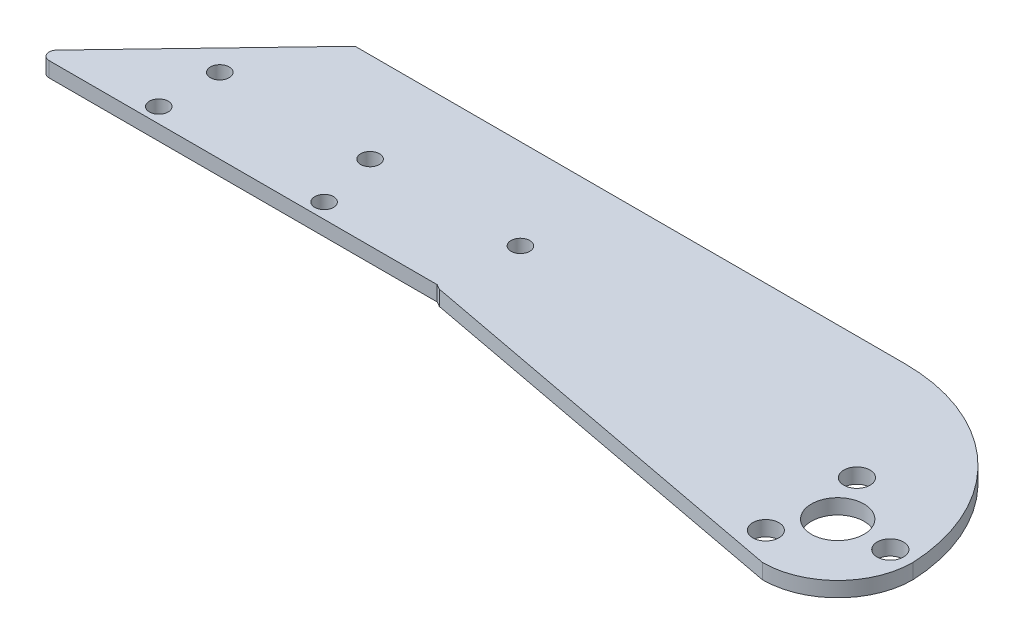
from build123d import *

# Parameters (mm, degrees)
SKETCH1_R                = 1.25
SKETCH1_R_2              = 1.75
BOSS_EXTRUDE1_DEPTH      = 2
FILLET_1_R               = 1
SKETCH_1_R               = 1.25
CUT_EXTRUDE_1_DEPTH      = 1
CUT_EXTRUDE_1_DEPTH_BACK = 3


with BuildPart() as part:
    # Sketch1 → Boss-Extrude1 (new body)
    with BuildSketch(Plane(origin=(0, 0, 0), x_dir=(1, 0, 0), z_dir=(0, 1, 0))):
        with BuildLine():
            Line((-13.417150151, 22.383876488), (-69.977405348, 22.383876488))
            Line((-69.977405348, 22.383876488), (-86.593533576, 22.383876488))
            Line((-86.593533576, 22.383876488), (-107.641374678, 0.375))
            Line((-107.641374678, 0.375), (-53.661481565, 0.375))
            Line((-53.661481565, 0.375), (-53, 0))
            Line((-53, 0), (0, -10))
            Line((0, -10), (0, -3.5))
            ThreePointArc((0, -3.5), (-3.5, 0), (0, 3.5))
            Line((0, 3.5), (0, 10))
            ThreePointArc((0, 10), (6.493821579, 7.604622364), (9.876612161, 1.566056261))
            ThreePointArc((9.876612161, 1.566056261), (2.20319717, 16.421011896), (-13.417150151, 22.383876488))
        make_face()
        with Locations((-92.705183178, 2.375)):
            Circle(SKETCH1_R, mode=Mode.SUBTRACT)
        with Locations((-70.705183178, 2.375)):
            Circle(SKETCH1_R, mode=Mode.SUBTRACT)
        with Locations((-3.5, -6.062177826)):
            Circle(SKETCH1_R_2, mode=Mode.SUBTRACT)
        with Locations((-3.5, 6.062177826)):
            Circle(SKETCH1_R_2, mode=Mode.SUBTRACT)
        with BuildLine():
            ThreePointArc((10, 0), (9.951428515, 0.784062032), (9.876612161, 1.566056261))
            ThreePointArc((9.876612161, 1.566056261), (6.493821579, 7.604622364), (0, 10))
            Line((0, 10), (0, 3.5))
            ThreePointArc((0, 3.5), (2.474873734, 2.474873734), (3.5, 0))
            ThreePointArc((3.5, 0), (2.474873734, -2.474873734), (0, -3.5))
            Line((0, -3.5), (0, -10))
            ThreePointArc((0, -10), (7.071067812, -7.071067812), (10, 0))
        make_face()
        with Locations((7, 0)):
            Circle(SKETCH1_R_2, mode=Mode.SUBTRACT)
    extrude(amount=BOSS_EXTRUDE1_DEPTH)

    # Скругление1
    fillet_1_edges = [part.edges().sort_by_distance(p)[0] for p in [
        (-107.641374678, 1, -0.375),
    ]]
    fillet(fillet_1_edges, radius=FILLET_1_R)

    # Эскиз1 → Вырез-Вытянуть1 (cut, two sides)
    with BuildSketch(Plane(origin=(0, 2, 0), x_dir=(1, 0, 0), z_dir=(0, 1, 0))) as cut_extrude_1_sk:
        with Locations((-92.593533576, 10.375)):
            Circle(SKETCH_1_R)
        with Locations((-72.593533576, 10.375)):
            Circle(SKETCH_1_R)
        with Locations((-52.593533576, 10.375)):
            Circle(SKETCH_1_R)
    extrude(amount=CUT_EXTRUDE_1_DEPTH, mode=Mode.SUBTRACT)
    extrude(cut_extrude_1_sk.sketch, amount=-CUT_EXTRUDE_1_DEPTH_BACK, mode=Mode.SUBTRACT)


solid = part.part
